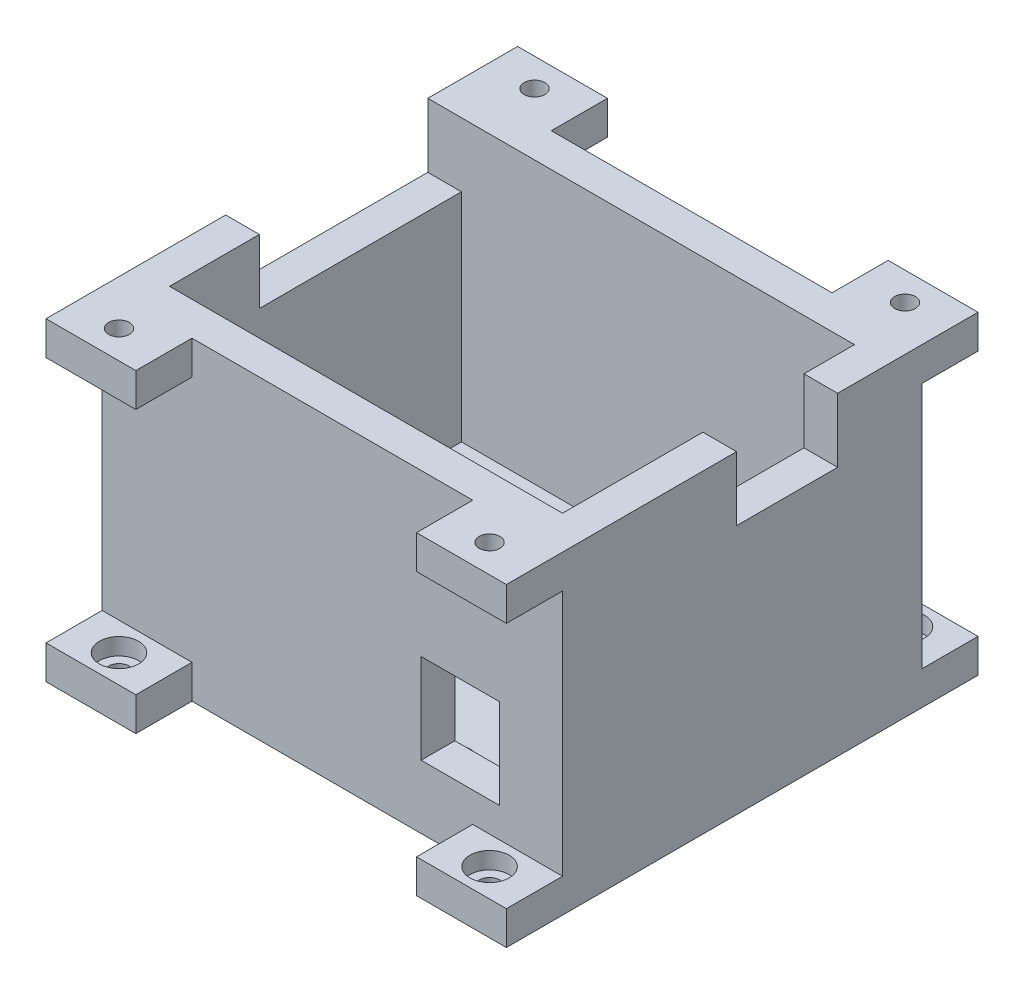
from build123d import *

# Parameters (mm, degrees)
SKETCH1_W                = 35
SKETCH1_H                = 26
SKETCH1_R                = 0.925
BOSS_EXTRUDE1_DEPTH      = 3
SKETCH2_R                = 1.389029916
CUT_EXTRUDE4_DEPTH       = 1.5
SKETCH3_W                = 41
SKETCH3_H                = 32
SKETCH3_W_2              = 35
SKETCH3_H_2              = 26
BOSS_EXTRUDE2_DEPTH      = 25
BOSS_EXTRUDE2_DEPTH_BACK = 3
SKETCH4_W                = 18
SKETCH4_H                = 5.71
CUT_EXTRUDE5_DEPTH       = 25
SKETCH5_W                = 9
SKETCH5_H                = 5.71
CUT_EXTRUDE6_DEPTH       = 25
SKETCH6_W                = 3
SKETCH6_H                = 3
CUT_EXTRUDE7_DEPTH       = 25
SKETCH8_W                = 7
SKETCH8_H                = 8
CUT_EXTRUDE8_DEPTH       = 25
SKETCH9_W                = 8
SKETCH9_H                = 3
BOSS_EXTRUDE3_DEPTH      = 5
SKETCH10_W               = 8
SKETCH10_H               = 3
BOSS_EXTRUDE4_DEPTH      = 5
SKETCH11_R               = 0.925
CUT_EXTRUDE9_DEPTH       = 5
SKETCH12_R               = 1.75
CUT_EXTRUDE10_DEPTH      = 1.5
SKETCH13_W               = 8
SKETCH13_H               = 3
BOSS_EXTRUDE5_DEPTH      = 5
SKETCH14_W               = 8
SKETCH14_H               = 3
BOSS_EXTRUDE6_DEPTH      = 5
SKETCH15_R               = 0.925
CUT_EXTRUDE11_DEPTH      = 5
SKETCH17_R               = 1.75
CUT_EXTRUDE13_DEPTH      = 1.5


with BuildPart() as part:
    # Sketch1 → Boss-Extrude1 (new body)
    with BuildSketch(Plane(origin=(0, 0, 0), x_dir=(1, 0, 0), z_dir=(0, 1, 0))):
        with Locations((9.357103431, 0.985655738)):
            Rectangle(SKETCH1_W, SKETCH1_H)
        with Locations((0.557103431, -10.236344262)):
            Circle(SKETCH1_R, mode=Mode.SUBTRACT)
        with Locations((15.924103431, -10.236344262)):
            Circle(SKETCH1_R, mode=Mode.SUBTRACT)
        with Locations((15.924103431, 11.607655738)):
            Circle(SKETCH1_R, mode=Mode.SUBTRACT)
    extrude(amount=BOSS_EXTRUDE1_DEPTH)

    # Sketch2 → Cut-Extrude4 (cut)
    with BuildSketch(Plane.XZ):
        with Locations((0.557103431, 10.236344262)):
            Circle(SKETCH2_R)
        with Locations((15.924103431, 10.236344262)):
            Circle(SKETCH2_R)
        with Locations((15.924103431, -11.607655738)):
            Circle(SKETCH2_R)
    extrude(amount=-CUT_EXTRUDE4_DEPTH, mode=Mode.SUBTRACT)

    # Sketch3 → Boss-Extrude2 (add, two sides)
    with BuildSketch(Plane(origin=(0, 3, 0), x_dir=(1, 0, 0), z_dir=(0, 1, 0))) as boss_extrude2_sk:
        with Locations((9.357103431, 0.985655738)):
            Rectangle(SKETCH3_W, SKETCH3_H)
        with Locations((9.357103431, 0.985655738)):
            Rectangle(SKETCH3_W_2, SKETCH3_H_2, mode=Mode.SUBTRACT)
    extrude(amount=BOSS_EXTRUDE2_DEPTH)
    extrude(boss_extrude2_sk.sketch, amount=-BOSS_EXTRUDE2_DEPTH_BACK)

    # Sketch4 → Cut-Extrude5 (cut)
    with BuildSketch(Plane(origin=(-8.142896569, 0, 0), x_dir=(0, 0, -1), z_dir=(1, 0, 0))):
        with Locations((4.985655738, 25.145)):
            Rectangle(SKETCH4_W, SKETCH4_H)
    extrude(amount=-CUT_EXTRUDE5_DEPTH, mode=Mode.SUBTRACT)

    # Sketch5 → Cut-Extrude6 (cut)
    with BuildSketch(Plane.ZY.offset(-26.857103431)):
        with Locations((-4.985655738, 25.145)):
            Rectangle(SKETCH5_W, SKETCH5_H)
    extrude(amount=-CUT_EXTRUDE6_DEPTH, mode=Mode.SUBTRACT)

    # Sketch6 → Cut-Extrude7 (cut)
    with BuildSketch(Plane(origin=(0, 3, 0), x_dir=(1, 0, 0), z_dir=(0, 1, 0))):
        with Locations((0.68611622, -7.236344262)):
            Rectangle(SKETCH6_W, SKETCH6_H)
    extrude(amount=-CUT_EXTRUDE7_DEPTH, mode=Mode.SUBTRACT)

    # Sketch8 → Cut-Extrude8 (cut)
    with BuildSketch(Plane.XY.offset(15.014344262)):
        with Locations((20.765233628, 9.653180084)):
            Rectangle(SKETCH8_W, SKETCH8_H)
    extrude(amount=-CUT_EXTRUDE8_DEPTH, mode=Mode.SUBTRACT)

    # Sketch9 → Boss-Extrude3 (add)
    with BuildSketch(Plane(origin=(0, 0, -16.985655738), x_dir=(-1, 0, 0), z_dir=(0, 0, -1))):
        with Locations((7.142896569, 1.5)):
            Rectangle(SKETCH9_W, SKETCH9_H)
        with Locations((-25.857103431, 1.5)):
            Rectangle(SKETCH9_W, SKETCH9_H)
    extrude(amount=BOSS_EXTRUDE3_DEPTH)

    # Sketch10 → Boss-Extrude4 (add)
    with BuildSketch(Plane.XY.offset(15.014344262)):
        with Locations((-7.142896569, 1.5)):
            Rectangle(SKETCH10_W, SKETCH10_H)
        with Locations((25.857103431, 1.5)):
            Rectangle(SKETCH10_W, SKETCH10_H)
    extrude(amount=BOSS_EXTRUDE4_DEPTH)

    # Sketch11 → Cut-Extrude9 (cut)
    with BuildSketch(Plane(origin=(0, 3, 0), x_dir=(1, 0, 0), z_dir=(0, 1, 0))):
        with Locations((-7.142896569, -17.514344262)):
            Circle(SKETCH11_R)
        with Locations((25.857103431, -17.514344262)):
            Circle(SKETCH11_R)
        with Locations((25.857103431, 19.485655738)):
            Circle(SKETCH11_R)
        with Locations((-7.142896569, 19.485655738)):
            Circle(SKETCH11_R)
    extrude(amount=-CUT_EXTRUDE9_DEPTH, mode=Mode.SUBTRACT)

    # Sketch12 → Cut-Extrude10 (cut)
    with BuildSketch(Plane(origin=(0, 3, 0), x_dir=(1, 0, 0), z_dir=(0, 1, 0))):
        with Locations((-7.142896569, -17.514344262)):
            Circle(SKETCH12_R)
        with Locations((-7.142896569, 19.485655738)):
            Circle(SKETCH12_R)
        with Locations((25.857103431, 19.485655738)):
            Circle(SKETCH12_R)
        with Locations((25.857103431, -17.514344262)):
            Circle(SKETCH12_R)
    extrude(amount=-CUT_EXTRUDE10_DEPTH, mode=Mode.SUBTRACT)

    # Sketch13 → Boss-Extrude5 (add)
    with BuildSketch(Plane.XY.offset(15.014344262)):
        with Locations((25.857103431, 26.5)):
            Rectangle(SKETCH13_W, SKETCH13_H)
        with Locations((-7.142896569, 26.5)):
            Rectangle(SKETCH13_W, SKETCH13_H)
    extrude(amount=BOSS_EXTRUDE5_DEPTH)

    # Sketch14 → Boss-Extrude6 (add)
    with BuildSketch(Plane(origin=(0, 0, -16.985655738), x_dir=(-1, 0, 0), z_dir=(0, 0, -1))):
        with Locations((-25.857103431, 26.5)):
            Rectangle(SKETCH14_W, SKETCH14_H)
        with Locations((7.142896569, 26.5)):
            Rectangle(SKETCH14_W, SKETCH14_H)
    extrude(amount=BOSS_EXTRUDE6_DEPTH)

    # Sketch15 → Cut-Extrude11 (cut)
    with BuildSketch(Plane.XZ.offset(-25)):
        with Locations((25.857103431, 17.514344262)):
            Circle(SKETCH15_R)
        with Locations((-7.142896569, 17.514344262)):
            Circle(SKETCH15_R)
        with Locations((25.857103431, -19.485655738)):
            Circle(SKETCH15_R)
        with Locations((-7.142896569, -19.485655738)):
            Circle(SKETCH15_R)
    extrude(amount=-CUT_EXTRUDE11_DEPTH, mode=Mode.SUBTRACT)

    # Sketch17 → Cut-Extrude13 (cut)
    with BuildSketch(Plane.XZ.offset(-25)):
        with Locations((25.857103431, -19.485655738)):
            Circle(SKETCH17_R)
        with Locations((25.857103431, 17.514344262)):
            Circle(SKETCH17_R)
        with Locations((-7.142896569, 17.514344262)):
            Circle(SKETCH17_R)
        with Locations((-7.142896569, -19.485655738)):
            Circle(SKETCH17_R)
    extrude(amount=-CUT_EXTRUDE13_DEPTH, mode=Mode.SUBTRACT)


solid = part.part
